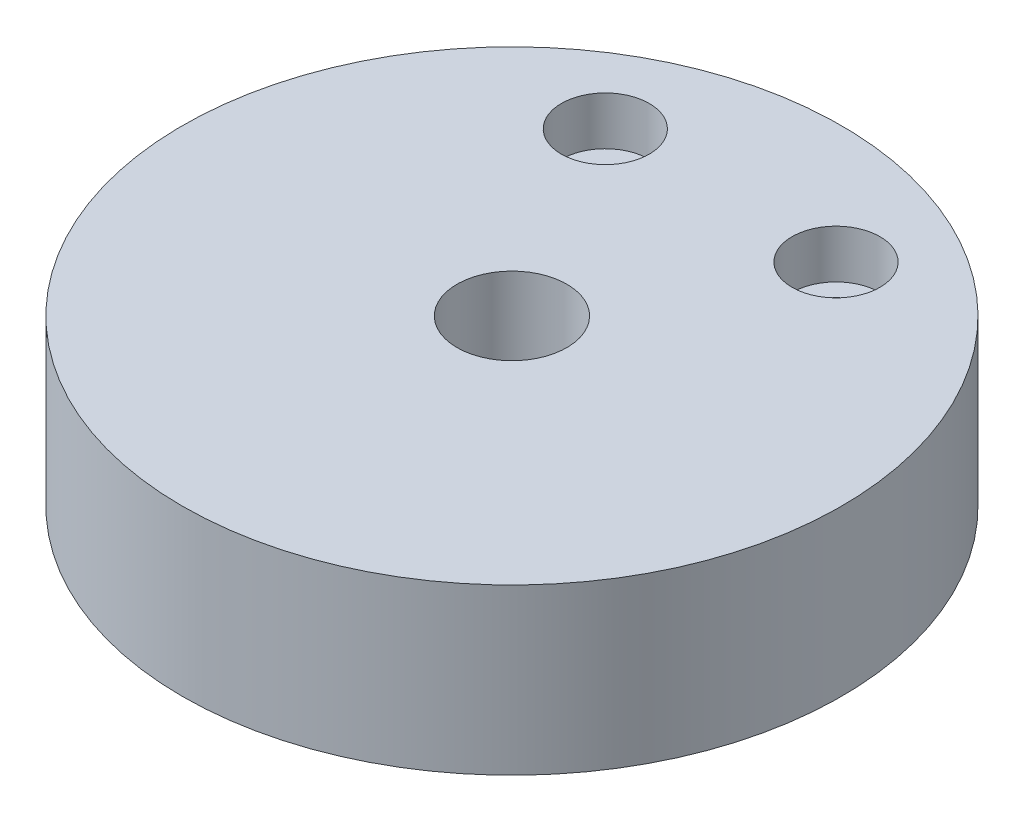
from build123d import *

# Parameters (mm, degrees)
SKETCH1_R                                           = 30
BOSS_EXTRUDE1_DEPTH                                 = 15
SKETCH10_R                                          = 5
CUT_EXTRUDE2_DEPTH                                  = 15
CBORE_FOR_M4_HEX_SOCKET_HEAD_CAP_SCREW3_D           = 4.5
CBORE_FOR_M4_HEX_SOCKET_HEAD_CAP_SCREW3_DEPTH       = 15
CBORE_FOR_M4_HEX_SOCKET_HEAD_CAP_SCREW3_CBORE_D     = 8
CBORE_FOR_M4_HEX_SOCKET_HEAD_CAP_SCREW3_CBORE_DEPTH = 4.4


with BuildPart() as part:
    # Sketch1 → Boss-Extrude1 (new body)
    with BuildSketch(Plane(origin=(0, 0, 0), x_dir=(1, 0, 0), z_dir=(0, 1, 0))):
        with Locations((121.722144349, 83.935831041)):
            Circle(SKETCH1_R)
    extrude(amount=BOSS_EXTRUDE1_DEPTH)

    # Sketch10 → Cut-Extrude2 (cut)
    with BuildSketch(Plane(origin=(0, 15, 0), x_dir=(1, 0, 0), z_dir=(0, 1, 0))):
        with Locations((121.722144349, 83.935831041)):
            Circle(SKETCH10_R)
    extrude(amount=-CUT_EXTRUDE2_DEPTH, mode=Mode.SUBTRACT)

    # CBORE for M4 Hex Socket Head Cap Screw3
    with Locations(Plane(origin=(132.222144349, 15, -102.935831041), x_dir=(0, 0, 1), z_dir=(0, 1, 0))):
        with Locations((0, 0), (0, -21)):
            CounterBoreHole(CBORE_FOR_M4_HEX_SOCKET_HEAD_CAP_SCREW3_D / 2, CBORE_FOR_M4_HEX_SOCKET_HEAD_CAP_SCREW3_CBORE_D / 2, CBORE_FOR_M4_HEX_SOCKET_HEAD_CAP_SCREW3_CBORE_DEPTH, depth=CBORE_FOR_M4_HEX_SOCKET_HEAD_CAP_SCREW3_DEPTH)


solid = part.part
